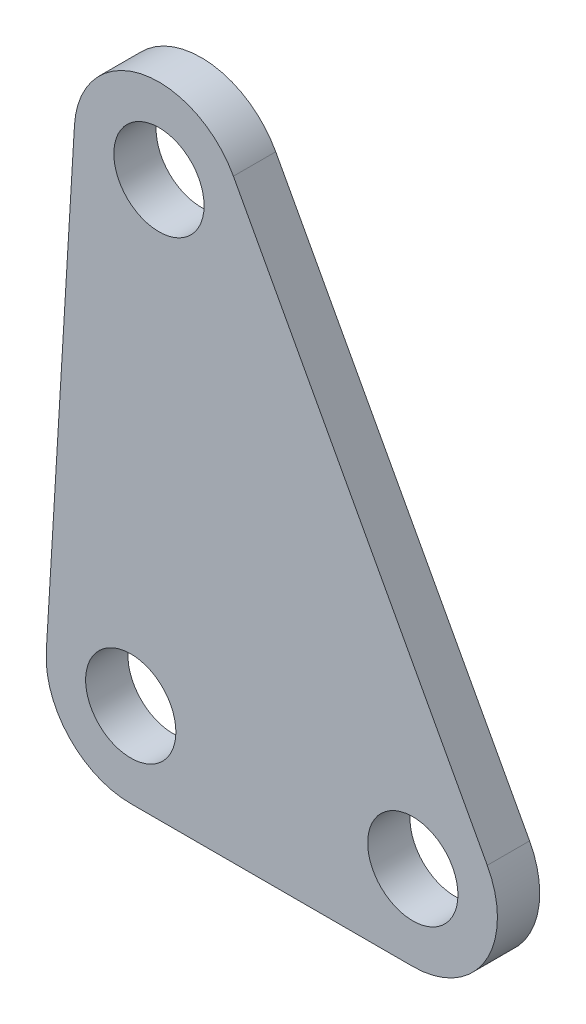
from build123d import *

# Parameters (mm, degrees)
SKETCH1_R           = 1.6
BOSS_EXTRUDE6_DEPTH = 1.5


with BuildPart() as part:
    # Sketch1 → Boss-Extrude6 (new body)
    with BuildSketch(Plane.XY):
        with BuildLine():
            Line((-1, -19.657819664), (9, -19.657819664))
            ThreePointArc((9, -19.657819664), (11.576635241, -18.194358252), (11.639399651, -15.231786885))
            Line((11.639399651, -15.231786885), (2.639399651, 1.426032778))
            ThreePointArc((2.639399651, 1.426032778), (-0.647946679, 2.929191885), (-2.99460883, 0.179771956))
            Line((-2.99460883, 0.179771956), (-3.99460883, -16.478047707))
            ThreePointArc((-3.99460883, -16.478047707), (-3.183954655, -18.714599201), (-1, -19.657819664))
        make_face()
        Circle(SKETCH1_R, mode=Mode.SUBTRACT)
        with Locations((9, -16.657819664)):
            Circle(SKETCH1_R, mode=Mode.SUBTRACT)
        with Locations((-1, -16.657819664)):
            Circle(SKETCH1_R, mode=Mode.SUBTRACT)
    extrude(amount=BOSS_EXTRUDE6_DEPTH)


solid = part.part
